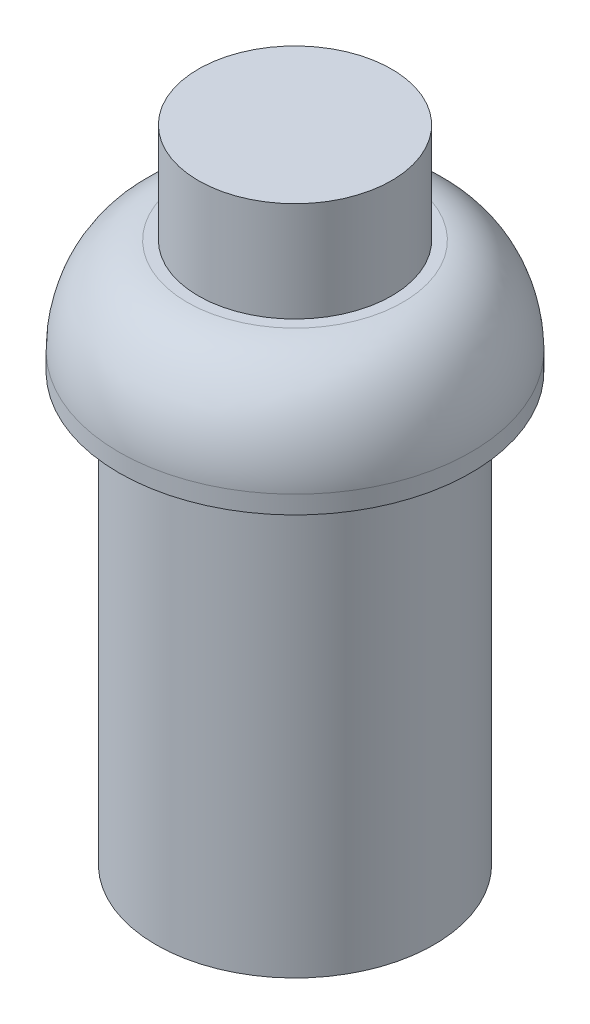
from build123d import *

# Parameters (mm, degrees)
SKETCH1_R           = 3.87
BOSS_EXTRUDE1_DEPTH = 11.89
SKETCH4_R           = 2.69
BOSS_EXTRUDE2_DEPTH = 2.78


with BuildPart() as part:
    # Sketch1 → Boss-Extrude1 (new body)
    with BuildSketch(Plane(origin=(0, 0, 0), x_dir=(1, 0, 0), z_dir=(0, 1, 0))):
        Circle(SKETCH1_R)
    extrude(amount=-BOSS_EXTRUDE1_DEPTH)

    # Sketch3 → Revolve1 (revolve)
    with BuildSketch(Plane.XY):
        with BuildLine():
            Line((0, 0), (0, 3.16))
            Line((0, 3.16), (3, 3.16))
            add(Edge.make_bspline(
                [(3, 3.16), (4.283639475, 3.024024765), (4.900890598, 1.632016655), (4.9, 0.5)],
                knots=[0, 0, 0, 0, 1, 1, 1, 1], degree=3))
            Line((4.9, 0.5), (4.9, 0))
            Line((4.9, 0), (0, 0))
        make_face()
    revolve(axis=Axis((0, 0, 0), (0, 1, 0)))

    # Sketch4 → Boss-Extrude2 (add)
    with BuildSketch(Plane(origin=(0, 3.16, 0), x_dir=(1, 0, 0), z_dir=(0, 1, 0))):
        Circle(SKETCH4_R)
    extrude(amount=BOSS_EXTRUDE2_DEPTH)


solid = part.part
